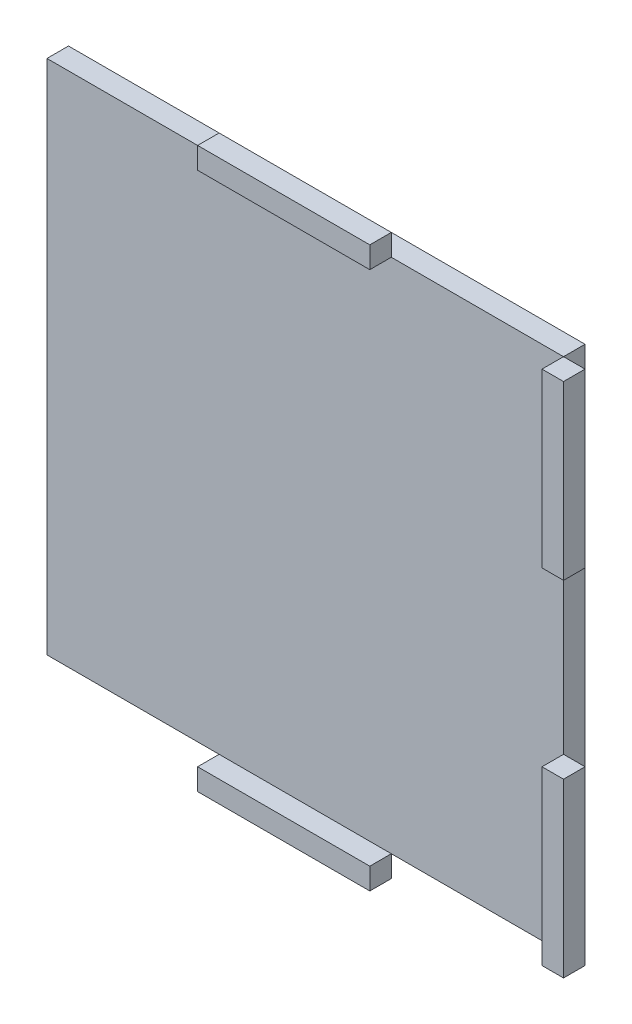
from build123d import *

# Parameters (mm, degrees)
SKETCH2_W             = 76.2
SKETCH2_H             = 76.2
BOSS_EXTRUDE1_DEPTH   = 3.175
SKETCH4_W             = 25.4
SKETCH4_H             = 3.175
BOSS_EXTRUDE3_DEPTH   = 3.175
SKETCH4_W_2           = 3.175
SKETCH4_H_2           = 25.4
BOSS_EXTRUDE3_2_DEPTH = 3.175
BOSS_EXTRUDE3_3_DEPTH = 3.175
BOSS_EXTRUDE3_4_DEPTH = 3.175


with BuildPart() as part:
    # Sketch2 → Boss-Extrude1 (new body)
    with BuildSketch(Plane.XY):
        Rectangle(SKETCH2_W, SKETCH2_H)
    extrude(amount=BOSS_EXTRUDE1_DEPTH)


with BuildPart() as body_2:
    # Sketch4 → Boss-Extrude3 (new body)
    with BuildSketch(Plane.XY.offset(3.175)):
        with Locations((0, -39.6875)):
            Rectangle(SKETCH4_W, SKETCH4_H)
    extrude(amount=BOSS_EXTRUDE3_DEPTH)


with BuildPart() as body_3:
    # Sketch4 → Boss-Extrude3 2 (new body)
    with BuildSketch(Plane.XY.offset(3.175)):
        with Locations((39.6875, 25.4)):
            Rectangle(SKETCH4_W_2, SKETCH4_H_2)
    extrude(amount=BOSS_EXTRUDE3_2_DEPTH)


with BuildPart() as body_4:
    # Sketch4 → Boss-Extrude3 3 (new body)
    with BuildSketch(Plane.XY.offset(3.175)):
        with Locations((39.6875, -25.4)):
            Rectangle(SKETCH4_W_2, SKETCH4_H_2)
    extrude(amount=BOSS_EXTRUDE3_3_DEPTH)


with BuildPart() as body_5:
    # Sketch4 → Boss-Extrude3 4 (new body)
    with BuildSketch(Plane.XY.offset(3.175)):
        with Locations((0, 39.6875)):
            Rectangle(SKETCH4_W, SKETCH4_H)
    extrude(amount=BOSS_EXTRUDE3_4_DEPTH)


solid = Compound([part.part, body_2.part, body_3.part, body_4.part, body_5.part])
